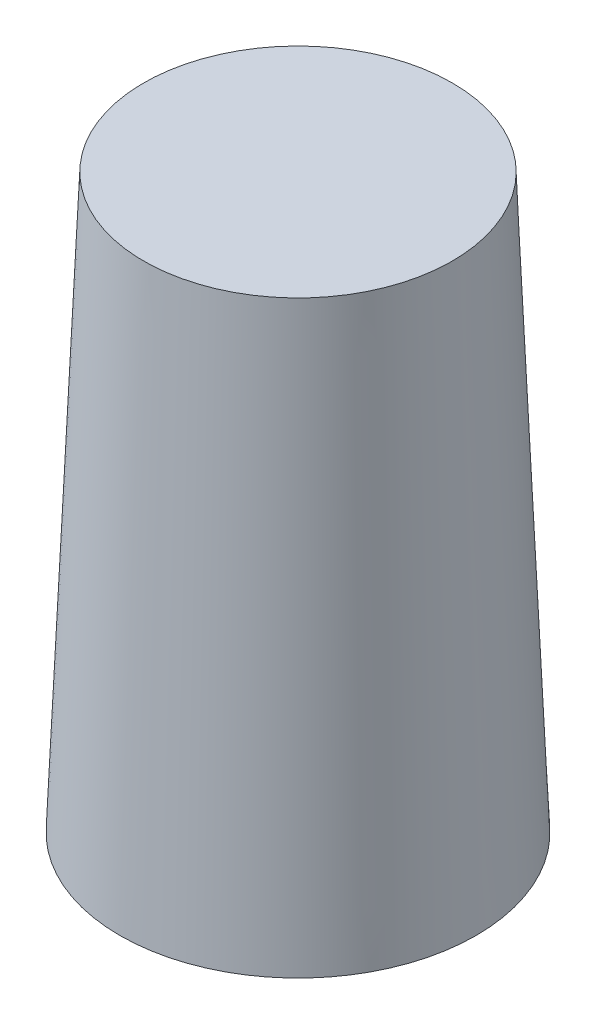
from build123d import *


with BuildPart() as part:
    # Sketch4 → Revolve1 (revolve)
    with BuildSketch(Plane.XY):
        Polygon((0, 0), (0, 2.54), (44.801956762, 2.54), (38.663623428, 149.86), (0, 149.86), (0, 152.4), (41.099994, 152.4), (47.449994, 0), align=None)
    revolve(axis=Axis((0, -7.62, 0), (0, 1, 0)))


solid = part.part
